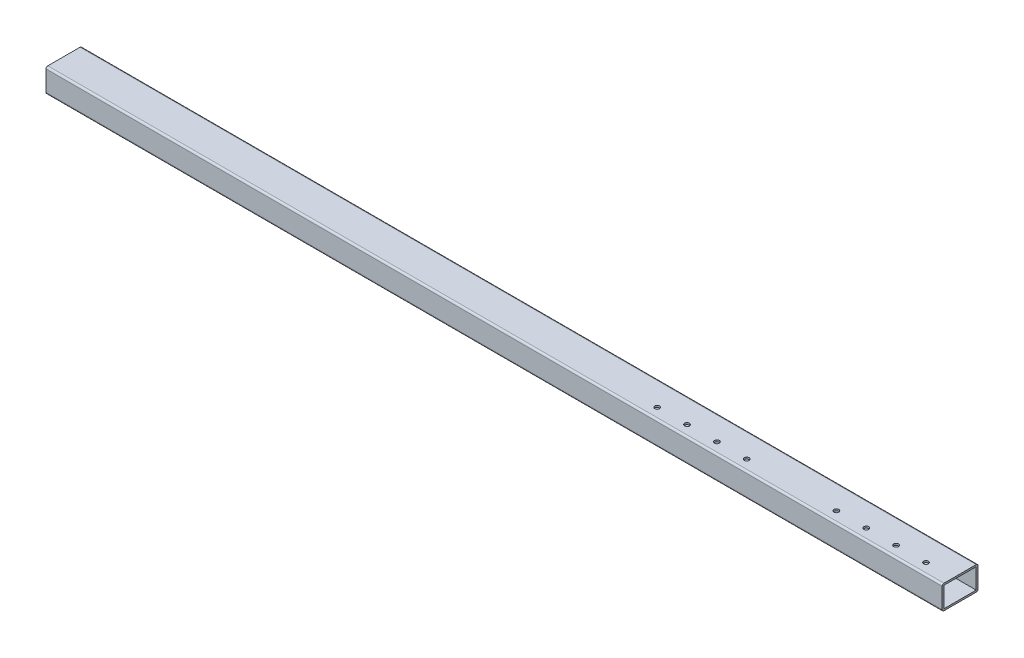
from build123d import *

# Parameters (mm, degrees)
SKETCH_1_W          = 54
SKETCH_1_H          = 34
EXTRUDE_1_DEPTH     = 1500
SKETCH_2_R          = 4.05
CUT_EXTRUDE_1_DEPTH = 41


with BuildPart() as part:
    # Эскиз1 → Вытянуть-Тонкостенный1 (new body)
    with BuildSketch(Plane(origin=(0, 0, 0), x_dir=(0, 0, -1), z_dir=(1, 0, 0))):
        with BuildLine():
            Line((30, 17), (30, -17))
            ThreePointArc((30, -17), (29.121320344, -19.121320344), (27, -20))
            Line((27, -20), (-27, -20))
            ThreePointArc((-27, -20), (-29.121320344, -19.121320344), (-30, -17))
            Line((-30, -17), (-30, 17))
            ThreePointArc((-30, 17), (-29.121320344, 19.121320344), (-27, 20))
            Line((-27, 20), (27, 20))
            ThreePointArc((27, 20), (29.121320344, 19.121320344), (30, 17))
        make_face()
        Rectangle(SKETCH_1_W, SKETCH_1_H, mode=Mode.SUBTRACT)
    extrude(amount=EXTRUDE_1_DEPTH)

    # Эскиз2 → Вырез-Вытянуть1 (cut, through all)
    with BuildSketch(Plane(origin=(0, 20, 0), x_dir=(1, 0, 0), z_dir=(0, 1, 0))):
        with Locations((1455, -12)):
            Circle(SKETCH_2_R)
        with Locations((1405, -12)):
            Circle(SKETCH_2_R)
        with Locations((1355, -12)):
            Circle(SKETCH_2_R)
        with Locations((1305, -12)):
            Circle(SKETCH_2_R)
        with Locations((1155, -12)):
            Circle(SKETCH_2_R)
        with Locations((1105, -12)):
            Circle(SKETCH_2_R)
        with Locations((1055, -12)):
            Circle(SKETCH_2_R)
        with Locations((1005, -12)):
            Circle(SKETCH_2_R)
    extrude(amount=-CUT_EXTRUDE_1_DEPTH, mode=Mode.SUBTRACT)


solid = part.part
